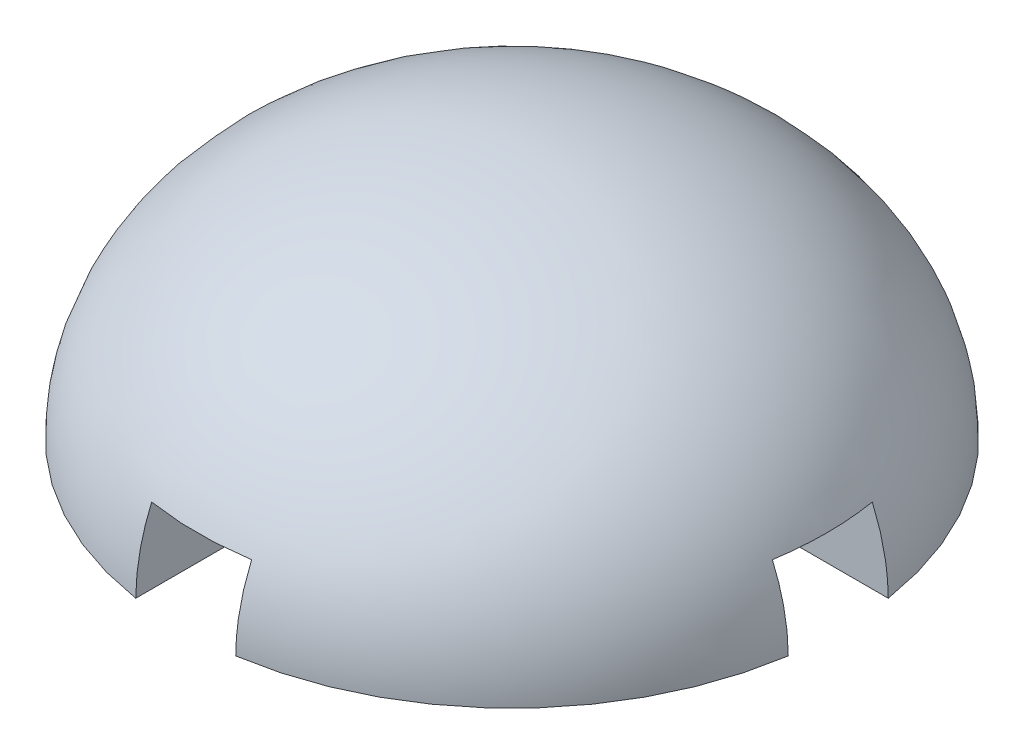
from build123d import *

# Parameters (mm, degrees)
SCALE1_SCALE_X      = 1
SCALE1_SCALE_Y      = 0.75
SCALE1_SCALE_Z      = 1
SKETCH3_W           = 5.3
SKETCH3_H           = 4
CUT_EXTRUDE1_DEPTH  = 17.5
CIRPATTERN1_COUNT   = 2
CIRPATTERN1_ANGLE   = 90
SKETCH4_R           = 2.5
SKETCH4_R_2         = 1
BOSS_EXTRUDE1_DEPTH = 4
SKETCH5_R           = 1
CUT_EXTRUDE2_DEPTH  = 7.5


with BuildPart() as part:
    # Sketch2 → Revolve1 (revolve)
    with BuildSketch(Plane.XY):
        with BuildLine():
            Line((0, 0), (0, 17.5))
            ThreePointArc((0, 17.5), (12.374368671, 12.374368671), (17.5, 0))
            Line((17.5, 0), (0, 0))
        make_face()
    revolve(axis=Axis((0, 0, 0), (0, 1, 0)))


with BuildPart() as part_1:
    # Scale1: scaled about (0, 6.5625, 0)
    add(part.part.scale((SCALE1_SCALE_X, SCALE1_SCALE_Y, SCALE1_SCALE_Z), about=(0, 6.5625, 0)))

    # Sketch3 → Cut-Extrude1 (cut, symmetric)
    with BuildSketch(Plane.XY):
        with Locations((0, 3.640625)):
            Rectangle(SKETCH3_W, SKETCH3_H)
    cut_extrude1 = extrude(amount=CUT_EXTRUDE1_DEPTH, both=True, mode=Mode.SUBTRACT)

    # CirPattern1: Cut-Extrude1 ×2 about axis
    cirpattern1_axis = Axis((0, 0.984375, 0), (0, 1, 0))
    for i in range(1, CIRPATTERN1_COUNT):
        add(cut_extrude1.rotate(cirpattern1_axis, i * CIRPATTERN1_ANGLE / (CIRPATTERN1_COUNT - 1)), mode=Mode.SUBTRACT)

    # Sketch4 → Boss-Extrude1 (add)
    with BuildSketch(Plane.XZ.offset(-5.640625)):
        Circle(SKETCH4_R)
        Circle(SKETCH4_R_2, mode=Mode.SUBTRACT)
    extrude(amount=BOSS_EXTRUDE1_DEPTH)

    # Sketch5 → Cut-Extrude2 (cut)
    with BuildSketch(Plane.XZ.offset(-5.640625)):
        Circle(SKETCH5_R)
    extrude(amount=-CUT_EXTRUDE2_DEPTH, mode=Mode.SUBTRACT)


solid = part_1.part
